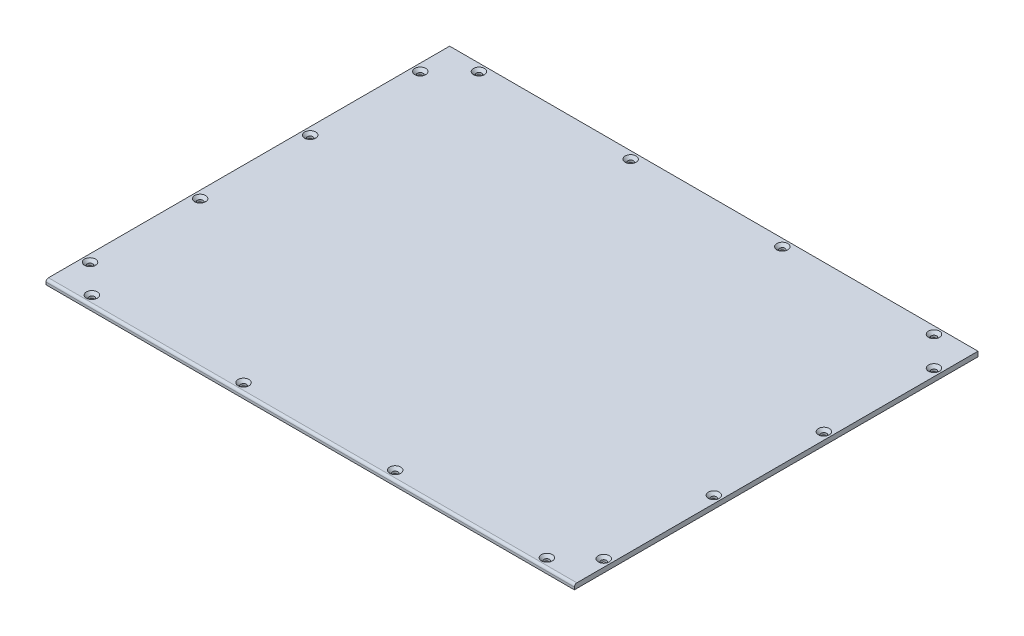
from build123d import *

# Parameters (mm, degrees)
SKETCH_1_W                   = 432
SKETCH_1_H                   = 330
EXTRUDE_1_DEPTH              = 4
HOLE_WIZARD_M4_1_AT_2_COUNT  = 2
HOLE_WIZARD_M4_1_AT_2_PITCH  = 90
HOLE_WIZARD_M4_1_AT_3_COUNT  = 2
HOLE_WIZARD_M4_1_AT_3_PITCH  = 180
HOLE_WIZARD_M4_1_AT_4_COUNT  = 2
HOLE_WIZARD_M4_1_AT_4_PITCH  = 270
HOLE_WIZARD_M4_1_AT_5_COUNT  = 2
HOLE_WIZARD_M4_1_AT_5_PITCH  = 293.48296373
HOLE_WIZARD_M4_1_AT_6_COUNT  = 2
HOLE_WIZARD_M4_1_AT_6_PITCH  = 327.811302429
HOLE_WIZARD_M4_1_AT_7_COUNT  = 2
HOLE_WIZARD_M4_1_AT_7_PITCH  = 399.424899074
HOLE_WIZARD_M4_1_AT_8_COUNT  = 2
HOLE_WIZARD_M4_1_AT_8_PITCH  = 492.31316253
HOLE_WIZARD_M4_1_AT_9_COUNT  = 2
HOLE_WIZARD_M4_1_AT_9_PITCH  = 499.299509313
HOLE_WIZARD_M4_1_AT_10_COUNT = 2
HOLE_WIZARD_M4_1_AT_10_PITCH = 456.946386352
HOLE_WIZARD_M4_1_AT_11_COUNT = 2
HOLE_WIZARD_M4_1_AT_11_PITCH = 429.534631898
HOLE_WIZARD_M4_1_AT_12_COUNT = 2
HOLE_WIZARD_M4_1_AT_12_PITCH = 420
HOLE_WIZARD_M4_1_AT_13_COUNT = 2
HOLE_WIZARD_M4_1_AT_13_PITCH = 396.726606116
HOLE_WIZARD_M4_1_AT_14_COUNT = 2
HOLE_WIZARD_M4_1_AT_14_PITCH = 273.056770654
HOLE_WIZARD_M4_1_AT_15_COUNT = 2
HOLE_WIZARD_M4_1_AT_15_PITCH = 149.933318512
HOLE_WIZARD_M4_1_AT_16_COUNT = 2
HOLE_WIZARD_M4_1_AT_16_PITCH = 33.941125497
FILLET_1_R                   = 2


with BuildPart() as part:
    # 草圖1 → 填料-伸長1 (new body)
    with BuildSketch(Plane(origin=(0, 0, 0), x_dir=(1, 0, 0), z_dir=(0, 1, 0))):
        with Locations((216, 165)):
            Rectangle(SKETCH_1_W, SKETCH_1_H)
    extrude(amount=EXTRUDE_1_DEPTH)

    # 草圖2 → M4 六角凹錐坑螺釘的錐孔1 (revolve, cut)
    with BuildSketch(Plane(origin=(6, 4, -300), x_dir=(0, 0, 1), z_dir=(1, 0, 0))):
        Polygon((0, 0), (0, 4), (2.25, 4), (2.25, 2.23), (4.48, 0), align=None)
    hole_wizard_m4_1 = revolve(axis=Axis((6, 10.35, -300), (0, -1, 0)), mode=Mode.SUBTRACT)

    # M4 六角凹錐坑螺釘的錐孔1 at 2: M4 六角凹錐坑螺釘的錐孔1 ×2
    with Locations(*[(0, 0, i * HOLE_WIZARD_M4_1_AT_2_PITCH) for i in range(1, HOLE_WIZARD_M4_1_AT_2_COUNT)]):
        add(hole_wizard_m4_1, mode=Mode.SUBTRACT)

    # M4 六角凹錐坑螺釘的錐孔1 at 3: M4 六角凹錐坑螺釘的錐孔1 ×2
    with Locations(*[(0, 0, i * HOLE_WIZARD_M4_1_AT_3_PITCH) for i in range(1, HOLE_WIZARD_M4_1_AT_3_COUNT)]):
        add(hole_wizard_m4_1, mode=Mode.SUBTRACT)

    # M4 六角凹錐坑螺釘的錐孔1 at 4: M4 六角凹錐坑螺釘的錐孔1 ×2
    with Locations(*[(0, 0, i * HOLE_WIZARD_M4_1_AT_4_PITCH) for i in range(1, HOLE_WIZARD_M4_1_AT_4_COUNT)]):
        add(hole_wizard_m4_1, mode=Mode.SUBTRACT)

    # M4 六角凹錐坑螺釘的錐孔1 at 5: M4 六角凹錐坑螺釘的錐孔1 ×2
    with Locations(*[Vector(0.081776467, 0, 0.996650696) * (i * HOLE_WIZARD_M4_1_AT_5_PITCH) for i in range(1, HOLE_WIZARD_M4_1_AT_5_COUNT)]):
        add(hole_wizard_m4_1, mode=Mode.SUBTRACT)

    # M4 六角凹錐坑螺釘的錐孔1 at 6: M4 六角凹錐坑螺釘的錐孔1 ×2
    with Locations(*[Vector(0.451479247, 0, 0.89228162) * (i * HOLE_WIZARD_M4_1_AT_6_PITCH) for i in range(1, HOLE_WIZARD_M4_1_AT_6_COUNT)]):
        add(hole_wizard_m4_1, mode=Mode.SUBTRACT)

    # M4 六角凹錐坑螺釘的錐孔1 at 7: M4 六角凹錐坑螺釘的錐孔1 ×2
    with Locations(*[Vector(0.680979079, 0, 0.73230287) * (i * HOLE_WIZARD_M4_1_AT_7_PITCH) for i in range(1, HOLE_WIZARD_M4_1_AT_7_COUNT)]):
        add(hole_wizard_m4_1, mode=Mode.SUBTRACT)

    # M4 六角凹錐坑螺釘的錐孔1 at 8: M4 六角凹錐坑螺釘的錐孔1 ×2
    with Locations(*[Vector(0.804366062, 0, 0.594134023) * (i * HOLE_WIZARD_M4_1_AT_8_PITCH) for i in range(1, HOLE_WIZARD_M4_1_AT_8_COUNT)]):
        add(hole_wizard_m4_1, mode=Mode.SUBTRACT)

    # M4 六角凹錐坑螺釘的錐孔1 at 9: M4 六角凹錐坑螺釘的錐孔1 ×2
    with Locations(*[Vector(0.841178475, 0, 0.540757591) * (i * HOLE_WIZARD_M4_1_AT_9_PITCH) for i in range(1, HOLE_WIZARD_M4_1_AT_9_COUNT)]):
        add(hole_wizard_m4_1, mode=Mode.SUBTRACT)

    # M4 六角凹錐坑螺釘的錐孔1 at 10: M4 六角凹錐坑螺釘的錐孔1 ×2
    with Locations(*[Vector(0.91914503, 0, 0.393919299) * (i * HOLE_WIZARD_M4_1_AT_10_PITCH) for i in range(1, HOLE_WIZARD_M4_1_AT_10_COUNT)]):
        add(hole_wizard_m4_1, mode=Mode.SUBTRACT)

    # M4 六角凹錐坑螺釘的錐孔1 at 11: M4 六角凹錐坑螺釘的錐孔1 ×2
    with Locations(*[Vector(0.977802414, 0, 0.209529089) * (i * HOLE_WIZARD_M4_1_AT_11_PITCH) for i in range(1, HOLE_WIZARD_M4_1_AT_11_COUNT)]):
        add(hole_wizard_m4_1, mode=Mode.SUBTRACT)

    # M4 六角凹錐坑螺釘的錐孔1 at 12: M4 六角凹錐坑螺釘的錐孔1 ×2
    with Locations(*[(i * HOLE_WIZARD_M4_1_AT_12_PITCH, 0, 0) for i in range(1, HOLE_WIZARD_M4_1_AT_12_COUNT)]):
        add(hole_wizard_m4_1, mode=Mode.SUBTRACT)

    # M4 六角凹錐坑螺釘的錐孔1 at 13: M4 六角凹錐坑螺釘的錐孔1 ×2
    with Locations(*[Vector(0.998168497, 0, -0.06049506) * (i * HOLE_WIZARD_M4_1_AT_13_PITCH) for i in range(1, HOLE_WIZARD_M4_1_AT_13_COUNT)]):
        add(hole_wizard_m4_1, mode=Mode.SUBTRACT)

    # M4 六角凹錐坑螺釘的錐孔1 at 14: M4 六角凹錐坑螺釘的錐孔1 ×2
    with Locations(*[Vector(0.99612985, 0, -0.08789381) * (i * HOLE_WIZARD_M4_1_AT_14_PITCH) for i in range(1, HOLE_WIZARD_M4_1_AT_14_COUNT)]):
        add(hole_wizard_m4_1, mode=Mode.SUBTRACT)

    # M4 六角凹錐坑螺釘的錐孔1 at 15: M4 六角凹錐坑螺釘的錐孔1 ×2
    with Locations(*[Vector(0.987105478, 0, -0.160071159) * (i * HOLE_WIZARD_M4_1_AT_15_PITCH) for i in range(1, HOLE_WIZARD_M4_1_AT_15_COUNT)]):
        add(hole_wizard_m4_1, mode=Mode.SUBTRACT)

    # M4 六角凹錐坑螺釘的錐孔1 at 16: M4 六角凹錐坑螺釘的錐孔1 ×2
    with Locations(*[Vector(0.707106781, 0, -0.707106781) * (i * HOLE_WIZARD_M4_1_AT_16_PITCH) for i in range(1, HOLE_WIZARD_M4_1_AT_16_COUNT)]):
        add(hole_wizard_m4_1, mode=Mode.SUBTRACT)

    # 圓角1
    fillet_1_edges = [part.edges().sort_by_distance(p)[0] for p in [
        (216, 4, 0),
    ]]
    fillet(fillet_1_edges, radius=FILLET_1_R)


solid = part.part
